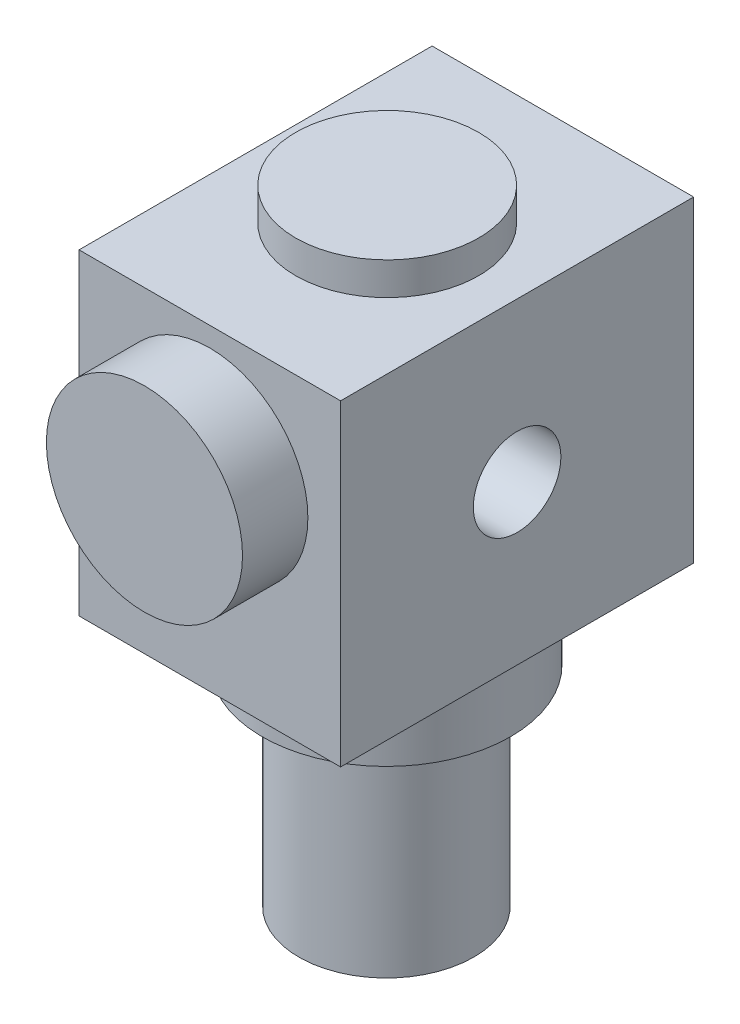
from build123d import *

# Parameters (mm, degrees)
SKETCH1_W           = 48.5
SKETCH1_H           = 40
BOSS_EXTRUDE1_DEPTH = 54
SKETCH2_R           = 15
BOSS_EXTRUDE2_DEPTH = 10
SKETCH3_R           = 14
BOSS_EXTRUDE3_DEPTH = 5
SKETCH4_R           = 19
BOSS_EXTRUDE4_DEPTH = 10
SKETCH5_R           = 13.38588386
BOSS_EXTRUDE5_DEPTH = 32
SKETCH6_R           = 6.7
CUT_EXTRUDE1_DEPTH  = 20
SKETCH7_R           = 6.7
CUT_EXTRUDE2_DEPTH  = 20


with BuildPart() as part:
    # Sketch1 → Boss-Extrude1 (new body)
    with BuildSketch(Plane(origin=(0, 0, 0), x_dir=(0, 1, 0), z_dir=(0, 0, 1))):
        Rectangle(SKETCH1_W, SKETCH1_H)
    extrude(amount=BOSS_EXTRUDE1_DEPTH)

    # Sketch2 → Boss-Extrude2 (add)
    with BuildSketch(Plane.XY.offset(54)):
        with Locations((0, 6.25)):
            Circle(SKETCH2_R)
    extrude(amount=BOSS_EXTRUDE2_DEPTH)

    # Sketch3 → Boss-Extrude3 (add)
    with BuildSketch(Plane(origin=(0, 24.25, 0), x_dir=(-1, 0, 0), z_dir=(0, 1, 0))):
        with Locations((0, 26.873266577)):
            Circle(SKETCH3_R)
    extrude(amount=BOSS_EXTRUDE3_DEPTH)

    # Sketch4 → Boss-Extrude4 (add)
    with BuildSketch(Plane.XZ.offset(24.25)):
        with Locations((0, 27)):
            Circle(SKETCH4_R)
    extrude(amount=BOSS_EXTRUDE4_DEPTH)

    # Sketch5 → Boss-Extrude5 (add)
    with BuildSketch(Plane.XZ.offset(34.25)):
        with Locations((0, 27)):
            Circle(SKETCH5_R)
    extrude(amount=BOSS_EXTRUDE5_DEPTH)

    # Sketch6 → Cut-Extrude1 (cut)
    with BuildSketch(Plane.YZ.offset(20)):
        with Locations((0, 27)):
            Circle(SKETCH6_R)
    extrude(amount=-CUT_EXTRUDE1_DEPTH, mode=Mode.SUBTRACT)

    # Sketch7 → Cut-Extrude2 (cut)
    with BuildSketch(Plane(origin=(-20, 0, 0), x_dir=(0, -1, 0), z_dir=(-1, 0, 0))):
        with Locations((0, 27)):
            Circle(SKETCH7_R)
    extrude(amount=-CUT_EXTRUDE2_DEPTH, mode=Mode.SUBTRACT)


solid = part.part
